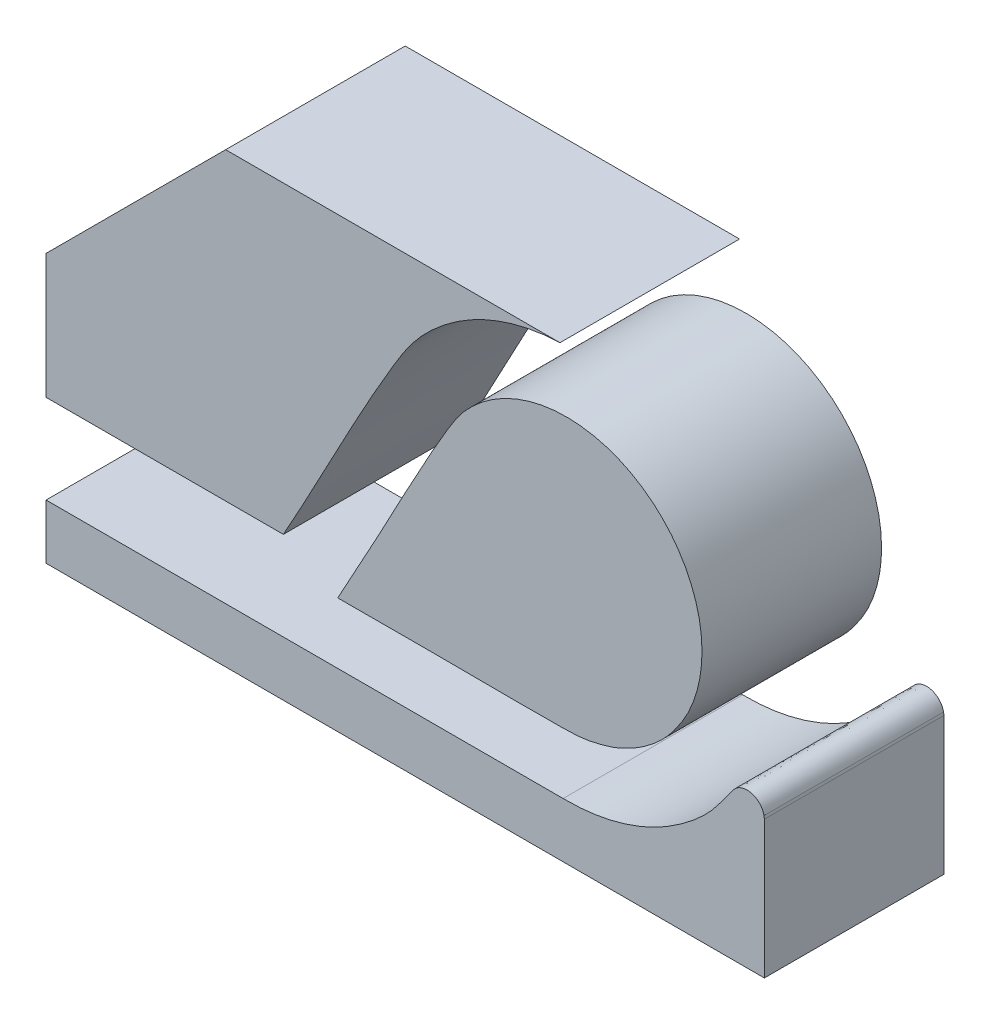
from build123d import *

# Parameters (mm, degrees)
BOSS_EXTRUDE1_DEPTH   = 5
BOSS_EXTRUDE1_2_DEPTH = 5
BOSS_EXTRUDE1_3_DEPTH = 5


with BuildPart() as part:
    # Sketch1 → Boss-Extrude1 (new body)
    with BuildSketch(Plane.XY):
        with BuildLine():
            Line((-76.51617055, 25.657864512), (-81.516170438, 20.657865555))
            Line((-81.516170438, 20.657865555), (-81.516170438, 17.185377182))
            Line((-81.516170438, 17.185377182), (-74.908736657, 17.185377182))
            add(Edge.make_bspline(
                [(-67.207032379, 25.657864512), (-67.841291205, 25.637703186), (-68.786007307, 25.438398136), (-69.92361055, 24.865003449), (-70.687202143, 24.292747989), (-71.349390259, 23.60157988), (-72.799306585, 21.241131816), (-73.867320183, 19.042669196), (-74.908736657, 17.185377182)],
                knots=[0, 0, 0, 0, 0.157242751, 0.235864252, 0.314485505, 0.393106931, 0.471729271, 1, 1, 1, 1], degree=3))
            Line((-67.207032379, 25.657864512), (-76.51617055, 25.657864512))
        make_face()
    extrude(amount=BOSS_EXTRUDE1_DEPTH)


with BuildPart() as body_2:
    # Sketch1 → Boss-Extrude1 2 (new body)
    with BuildSketch(Plane.XY):
        with BuildLine():
            add(Edge.make_bspline(
                [(-73.394955631, 16.410378964), (-73.027741911, 17.075731885), (-72.006593585, 18.92594604), (-70.949070194, 20.995177978), (-70.023413086, 22.518583228), (-69.58416794, 22.985848415), (-69.078131783, 23.376638303), (-68.512122047, 23.67571545), (-67.904284314, 23.875664619), (-67.271376225, 23.970507697), (-66.631559551, 23.957613713), (-66.003009348, 23.837333703), (-65.403629883, 23.613096715), (-64.850477427, 23.291286974), (-64.359302234, 22.88105956), (-63.944084412, 22.394097336), (-63.616641687, 21.844257809), (-63.386308, 21.247202264), (-63.259583254, 20.619896495), (-63.240299322, 19.980305713), (-63.328153933, 19.346239154), (-63.496315171, 18.822873267), (-63.655559595, 18.476950741), (-63.870222743, 18.110681823), (-64.165895591, 17.685772713), (-64.58889088, 17.290465931), (-64.932267574, 17.039885804), (-65.205082211, 16.874118433), (-65.49116247, 16.73309075), (-65.737595602, 16.632447716), (-65.992580682, 16.557928262), (-66.198406139, 16.505351645), (-66.457934661, 16.448819283), (-66.722449899, 16.417811158), (-67.735945429, 16.392628307), (-69.739735374, 16.421308639), (-71.780574498, 16.410073592), (-73.020374226, 16.410347303), (-73.163783896, 16.410378964)],
                knots=[0, 0, 0, 0, 0.080304634, 0.223311218, 0.245748751, 0.268186212, 0.290623796, 0.31306126, 0.33549875, 0.357936209, 0.380373827, 0.402811344, 0.425248838, 0.447686333, 0.470123867, 0.492561384, 0.514998857, 0.537436397, 0.559873936, 0.582311432, 0.604748903, 0.627186439, 0.640157589, 0.644900539, 0.672052802, 0.694490331, 0.705719062, 0.716947813, 0.7281766, 0.739405359, 0.745019744, 0.756238517, 0.761852914, 0.773081652, 0.784310437, 0.868971772, 0.98484375, 1, 1, 1, 1], degree=3))
            Line((-73.394955631, 16.410378964), (-73.163783896, 16.410378964))
        make_face()
    extrude(amount=BOSS_EXTRUDE1_2_DEPTH)


with BuildPart() as body_3:
    # Sketch1 → Boss-Extrude1 3 (new body)
    with BuildSketch(Plane.XY):
        with BuildLine():
            Line((-81.516170438, 14.710378126), (-81.516170438, 13.184251488))
            Line((-81.516170438, 13.184251488), (-61.516170885, 13.184251488))
            Line((-61.516170885, 13.184251488), (-61.516170885, 17.015781478))
            Line((-61.516170885, 17.015781478), (-61.526150938, 17.094897331))
            add(Edge.make_bspline(
                [(-67.041171279, 14.710378126), (-66.731164983, 14.712155209), (-66.118009533, 14.758894563), (-65.219920502, 14.990382477), (-64.510809923, 15.304042858), (-63.991676042, 15.62496919), (-63.487216529, 15.988085062), (-62.916532724, 16.510148844), (-62.565024786, 17.050517279), (-62.342332632, 17.335349088), (-62.280984894, 17.387135132), (-62.212581007, 17.428684217), (-62.138083735, 17.458213304), (-62.059783405, 17.475095094), (-61.979757887, 17.478809868), (-61.900219285, 17.469275828), (-61.823344916, 17.446744662), (-61.751234141, 17.41184652), (-61.685889623, 17.365518046), (-61.629025833, 17.309058934), (-61.582461873, 17.243950175), (-61.546517334, 17.172199755), (-61.532671384, 17.120697681), (-61.526150938, 17.094897331)],
                knots=[0.433439487, 0.433439487, 0.433439487, 0.433439487, 0.485344665, 0.537249839, 0.589155041, 0.615107636, 0.641060231, 0.692965396, 0.744870567, 0.749356682, 0.753842781, 0.758328884, 0.762814934, 0.767301114, 0.771787169, 0.776273249, 0.780759382, 0.785245497, 0.78973159, 0.794217734, 0.798703799, 0.803189925, 0.807676026, 0.807676026, 0.807676026, 0.807676026], degree=3))
            Line((-67.041171279, 14.710378126), (-81.516170438, 14.710378126))
        make_face()
    extrude(amount=BOSS_EXTRUDE1_3_DEPTH)


solid = Compound([part.part, body_2.part, body_3.part])
